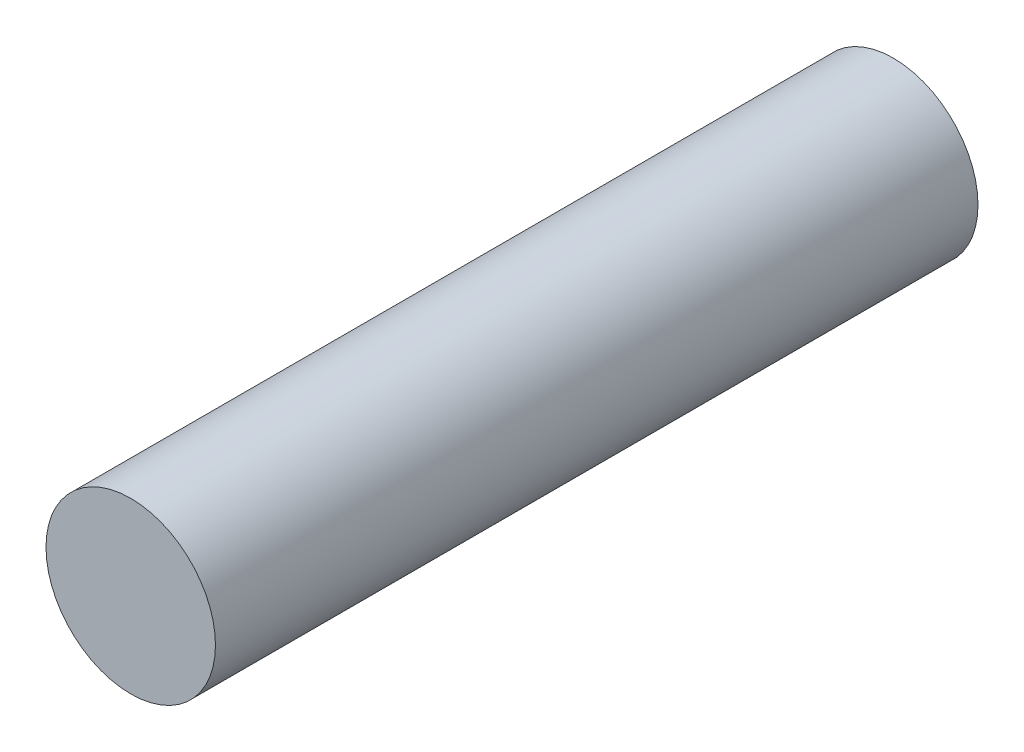
from build123d import *

# Parameters (mm, degrees)
SKETCH1_R           = 10
BOSS_EXTRUDE1_DEPTH = 45


with BuildPart() as part:
    # Sketch1 → Boss-Extrude1 (new body, symmetric)
    with BuildSketch(Plane.XY):
        Circle(SKETCH1_R)
    extrude(amount=BOSS_EXTRUDE1_DEPTH, both=True)


solid = part.part
